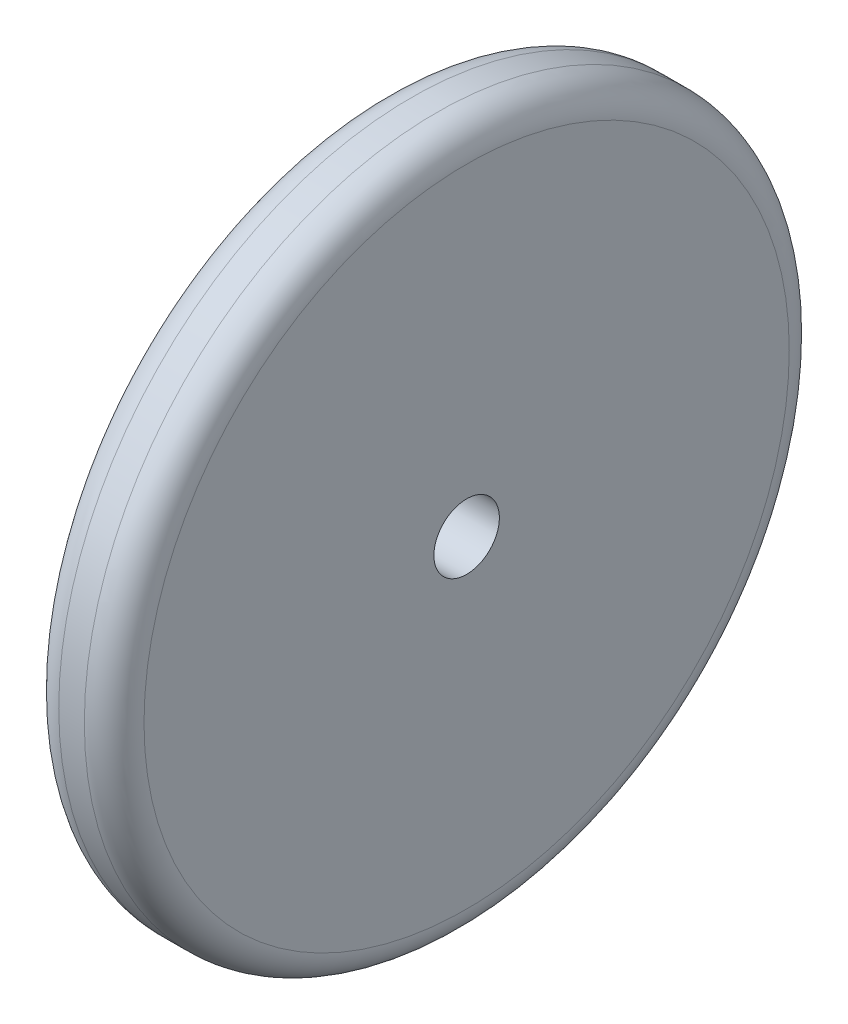
from build123d import *

# Parameters (mm, degrees)
SKETCH2_W = 5.08
SKETCH2_H = 19.05
FILLET1_R = 1.778


with BuildPart() as part:
    # Sketch2 → Revolve1 (revolve)
    with BuildSketch(Plane(origin=(0, 0, 18.152779015), x_dir=(-1, 0, 0), z_dir=(0, 0, -1))):
        with Locations((76.094049076, -87.93904144)):
            Rectangle(SKETCH2_W, SKETCH2_H)
    revolve(axis=Axis((-88.154662924, -99.41404144, 18.152779015), (1, 0, 0)))

    # Fillet1
    fillet1_edges = [part.edges().sort_by_distance(p)[0] for p in [
        (-78.634049076, -120.41404144, 18.152779015),
        (-73.554049076, -120.41404144, 18.152779015),
    ]]
    fillet(fillet1_edges, radius=FILLET1_R)


solid = part.part
